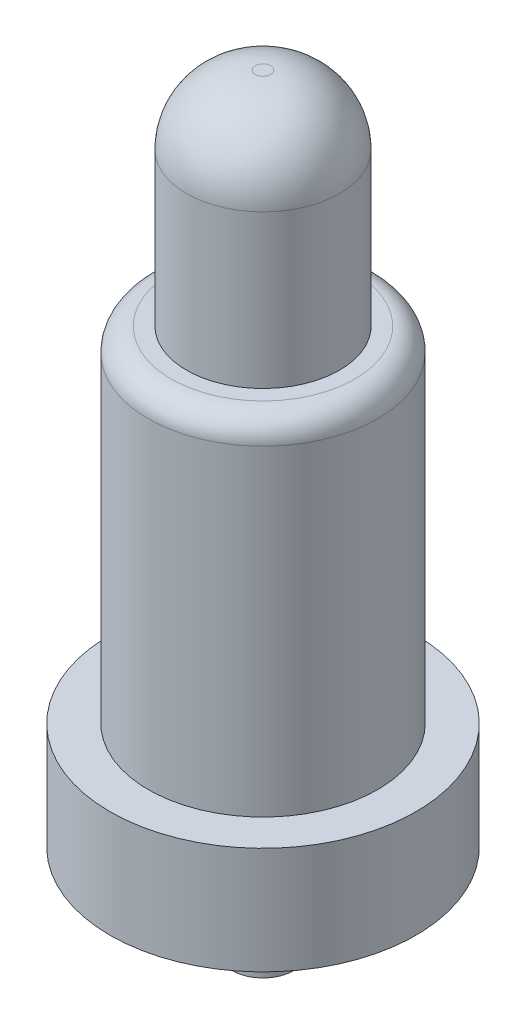
from build123d import *


with BuildPart() as part:
    # Sketch1 → Revolve1 (revolve)
    with BuildSketch(Plane.XY):
        with BuildLine():
            Line((0, 0), (-0.2, 0))
            Line((-0.2, 0), (-0.2, 0.6))
            Line((-0.2, 0.6), (-1, 0.6))
            Line((-1, 0.6), (-1, 1.3))
            Line((-1, 1.3), (-0.75, 1.3))
            Line((-0.75, 1.3), (-0.75, 3.4))
            ThreePointArc((-0.75, 3.4), (-0.706066017, 3.506066017), (-0.6, 3.55))
            Line((-0.6, 3.55), (-0.5, 3.55))
            Line((-0.5, 3.55), (-0.5, 4.55))
            ThreePointArc((-0.5, 4.55), (-0.368198052, 4.868198052), (-0.05, 5))
            Line((-0.05, 5), (0, 5))
            Line((0, 5), (0, 0))
        make_face()
    revolve(axis=Axis((0, 0, 0), (0, 1, 0)))


solid = part.part
